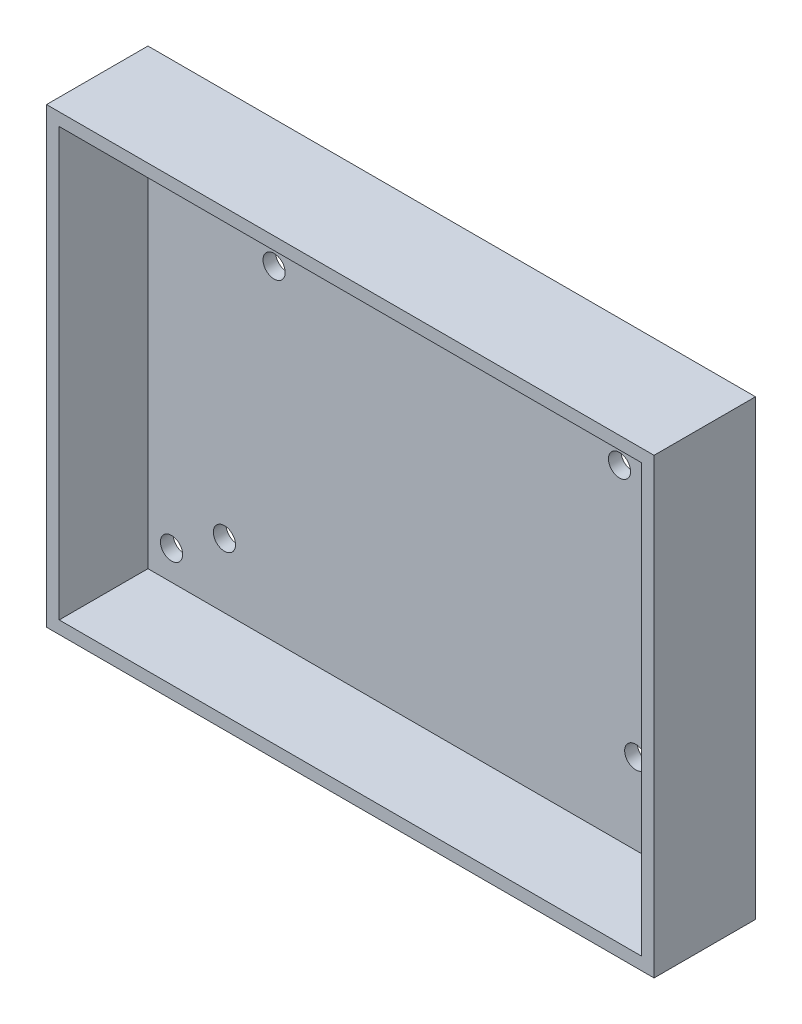
from build123d import *

# Parameters (mm, degrees)
SKETCH1_W           = 191.709364395
SKETCH1_H           = 142.845926684
SKETCH1_R           = 3.5
BOSS_EXTRUDE2_DEPTH = 4
SKETCH1_5_W         = 183.709364395
SKETCH1_5_H         = 134.845926684
BOSS_EXTRUDE3_DEPTH = 32


with BuildPart() as part:
    # Sketch1 → Boss-Extrude2 (new body)
    with BuildSketch(Plane.XY):
        with Locations((163.587328245, -1.577036658)):
            Rectangle(SKETCH1_W, SKETCH1_H)
        with Locations((94.973221843, 44.766341696)):
            Circle(SKETCH1_R, mode=Mode.SUBTRACT)
        with Locations((111.546962379, 33.572096538)):
            Circle(SKETCH1_R, mode=Mode.SUBTRACT)
        with Locations((220.528931491, 33.685981472)):
            Circle(SKETCH1_R, mode=Mode.SUBTRACT)
        with Locations((237.21688879, 44.709233314)):
            Circle(SKETCH1_R, mode=Mode.SUBTRACT)
        with Locations((79.183060399, -59.680217036)):
            Circle(SKETCH1_R, mode=Mode.SUBTRACT)
        with Locations((95.871017698, -48.656965194)):
            Circle(SKETCH1_R, mode=Mode.SUBTRACT)
        with Locations((242.235781203, -54.69781901)):
            Circle(SKETCH1_R, mode=Mode.SUBTRACT)
        with Locations((225.662040668, -43.503573852)):
            Circle(SKETCH1_R, mode=Mode.SUBTRACT)
    extrude(amount=BOSS_EXTRUDE2_DEPTH)

    # Sketch1_5 → Boss-Extrude3 (add)
    with BuildSketch(Plane.XY):
        Polygon((259.442010442, -73), (259.442010442, -1.577036658), (259.442010442, 69.845926684), (67.732646047, 69.845926684), (67.732646047, -73), (163.587328244, -73), align=None)
        with Locations((163.587328245, -1.577036658)):
            Rectangle(SKETCH1_5_W, SKETCH1_5_H, mode=Mode.SUBTRACT)
    extrude(amount=BOSS_EXTRUDE3_DEPTH)


solid = part.part
